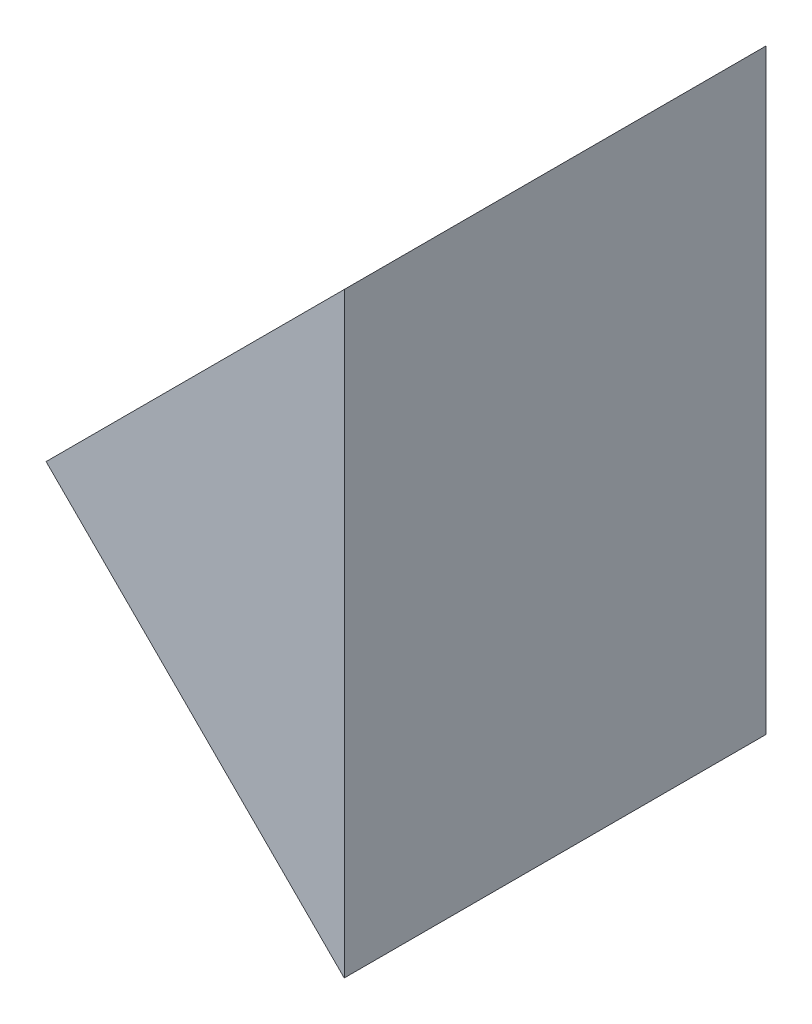
from build123d import *

# Parameters (mm, degrees)
EXTRUDE_1_DEPTH = 25


with BuildPart() as part:
    # 草图1 → 凸台-拉伸1 (new body)
    with BuildSketch(Plane.XY):
        Polygon((277.383349763, 68.878462764), (295.061019293, 86.556132294), (295.061019293, 51.200793235), align=None)
    extrude(amount=EXTRUDE_1_DEPTH)


solid = part.part
